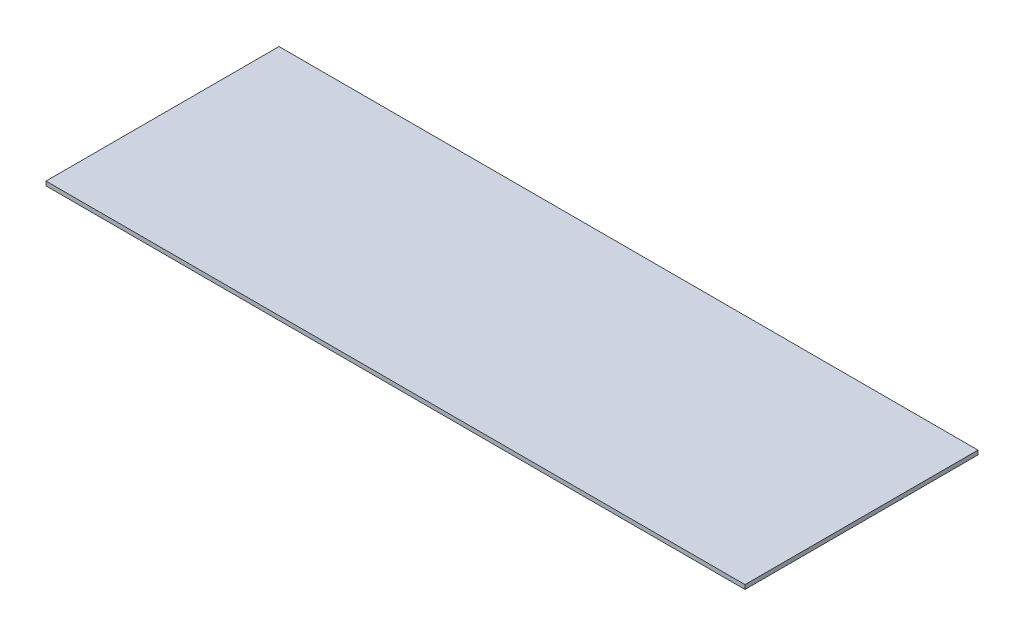
from build123d import *

# Parameters (mm, degrees)
SKETCH_1_W      = 300
SKETCH_1_H      = 100
EXTRUDE_1_DEPTH = 1.8


with BuildPart() as part:
    # 草图1 → 凸台-拉伸1 (new body)
    with BuildSketch(Plane(origin=(0, 0, 0), x_dir=(1, 0, 0), z_dir=(0, 1, 0))):
        with Locations((150, 50)):
            Rectangle(SKETCH_1_W, SKETCH_1_H)
    extrude(amount=EXTRUDE_1_DEPTH)


solid = part.part
